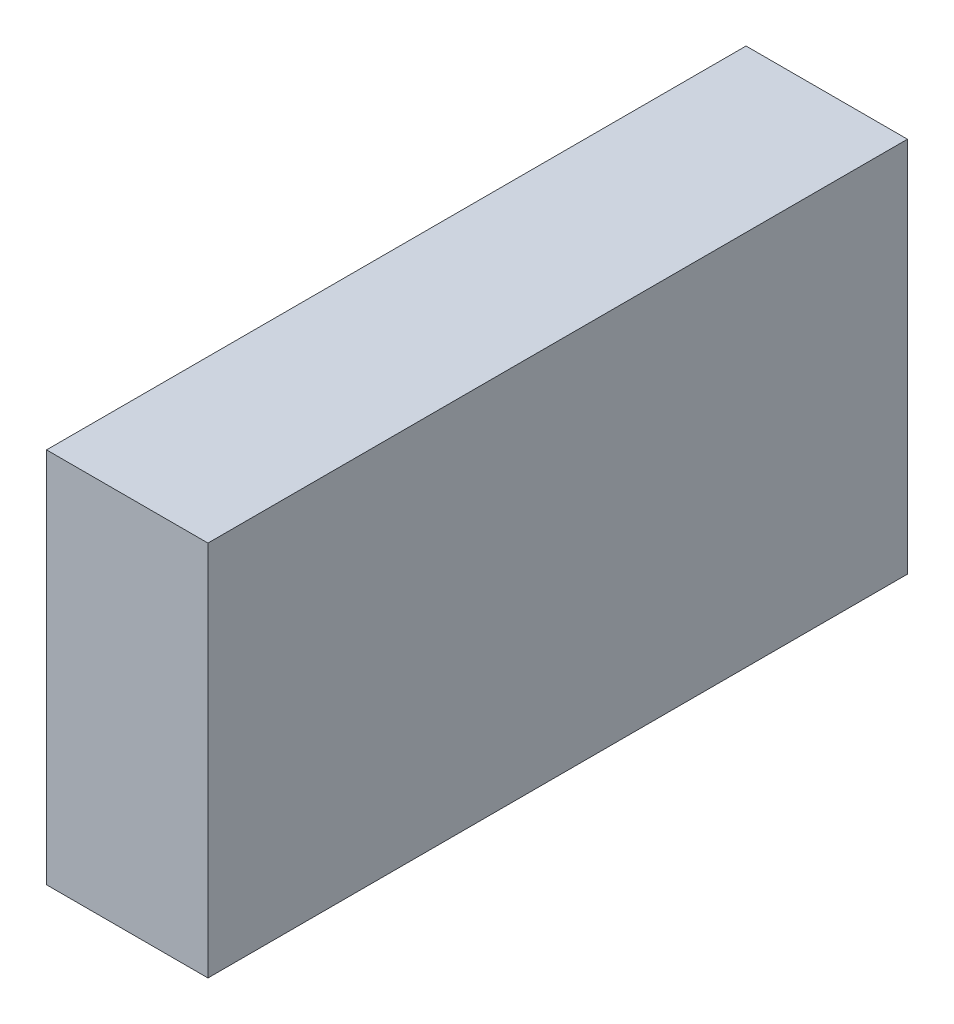
from build123d import *

# Parameters (mm, degrees)
SKETCH1_W           = 38.1
SKETCH1_H           = 88.9
BOSS_EXTRUDE1_DEPTH = 82.55


with BuildPart() as part:
    # Sketch1 → Boss-Extrude1 (new body, symmetric)
    with BuildSketch(Plane.XY):
        Rectangle(SKETCH1_W, SKETCH1_H)
    extrude(amount=BOSS_EXTRUDE1_DEPTH, both=True)


solid = part.part
